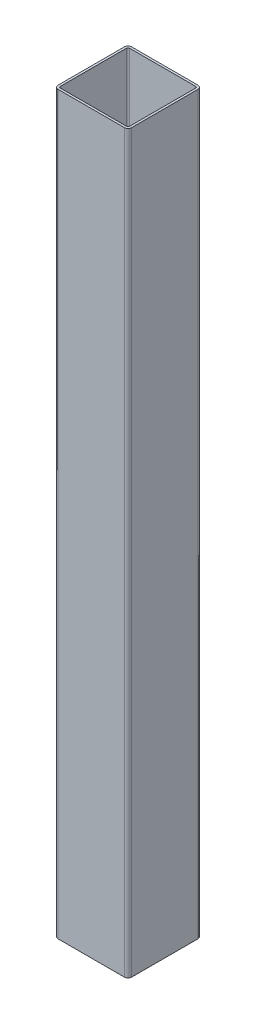
from build123d import *

# Parameters (mm, degrees)
EXTRUDE_1_DEPTH = 1000


with BuildPart() as part:
    # Эскиз1 → Вытянуть-Тонкостенный1 (new body)
    with BuildSketch(Plane(origin=(0, 0, 0), x_dir=(1, 0, 0), z_dir=(0, 1, 0))):
        with BuildLine():
            Line((-50, -45), (-50, 45))
            ThreePointArc((-50, 45), (-48.535533906, 48.535533906), (-45, 50))
            Line((-45, 50), (45, 50))
            ThreePointArc((45, 50), (48.535533906, 48.535533906), (50, 45))
            Line((50, 45), (50, -45))
            ThreePointArc((50, -45), (48.535533906, -48.535533906), (45, -50))
            Line((45, -50), (-45, -50))
            ThreePointArc((-45, -50), (-48.535533906, -48.535533906), (-50, -45))
        make_face()
        with BuildLine():
            Line((-47, -45), (-47, 45))
            ThreePointArc((-47, 45), (-46.414213562, 46.414213562), (-45, 47))
            Line((-45, 47), (45, 47))
            ThreePointArc((45, 47), (46.414213562, 46.414213562), (47, 45))
            Line((47, 45), (47, -45))
            ThreePointArc((47, -45), (46.414213562, -46.414213562), (45, -47))
            Line((45, -47), (-45, -47))
            ThreePointArc((-45, -47), (-46.414213562, -46.414213562), (-47, -45))
        make_face(mode=Mode.SUBTRACT)
    extrude(amount=EXTRUDE_1_DEPTH)


solid = part.part
